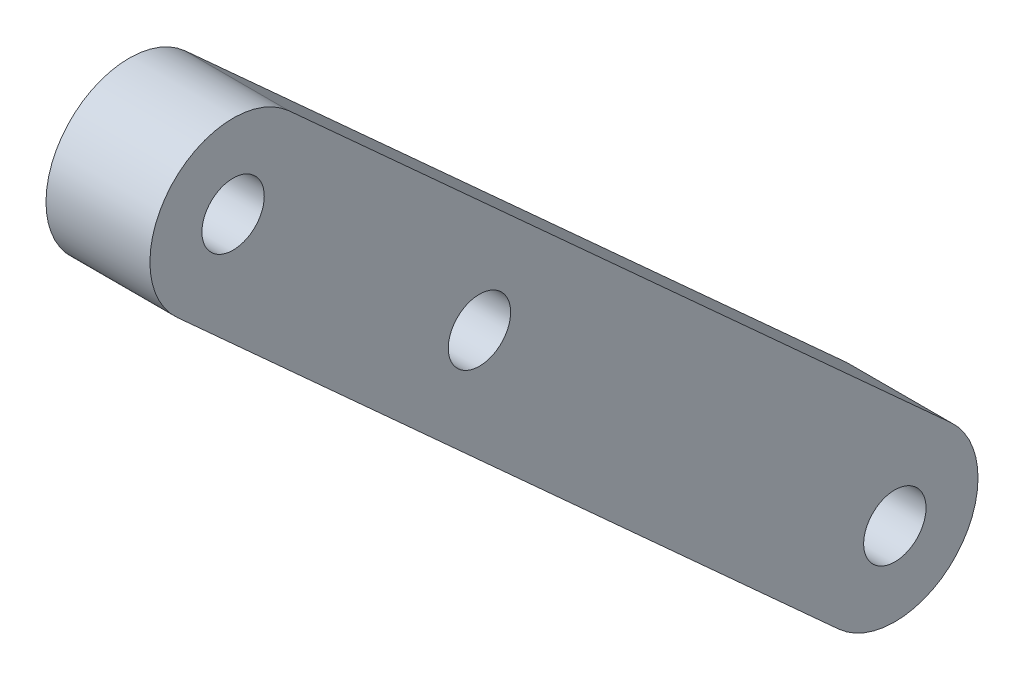
from build123d import *

# Parameters (mm, degrees)
SKETCH2_R           = 1.5
SKETCH2_R_2         = 4
BOSS_EXTRUDE1_DEPTH = 5


with BuildPart() as part:
    # Sketch2 → Boss-Extrude1 (new body)
    with BuildSketch(Plane(origin=(0, 0, 0), x_dir=(0, 0, -1), z_dir=(1, 0, 0))):
        with BuildLine():
            Line((92.352467742, 33.761940445), (60.516758506, 62.666743117))
            ThreePointArc((60.516758506, 62.666743117), (61.485484965, 61.324652748), (61.827939653, 59.705281792))
            ThreePointArc((61.827939653, 59.705281792), (59.447310609, 56.047736481), (55.1391208, 56.743820468))
            Line((55.1391208, 56.743820468), (86.974830036, 27.839017797))
            ThreePointArc((86.974830036, 27.839017797), (86.702187565, 33.489297974), (92.352467742, 33.761940445))
        make_face()
        with Locations((69.679349119, 48.944954468)):
            Circle(SKETCH2_R, mode=Mode.SUBTRACT)
        with Locations((57.827939653, 59.705281792)):
            Circle(SKETCH2_R_2)
        with Locations((57.827939653, 59.705281792)):
            Circle(SKETCH2_R, mode=Mode.SUBTRACT)
        with Locations((89.663648889, 30.800479121)):
            Circle(SKETCH2_R_2)
        with Locations((89.663648889, 30.800479121)):
            Circle(SKETCH2_R, mode=Mode.SUBTRACT)
    extrude(amount=BOSS_EXTRUDE1_DEPTH)


solid = part.part
